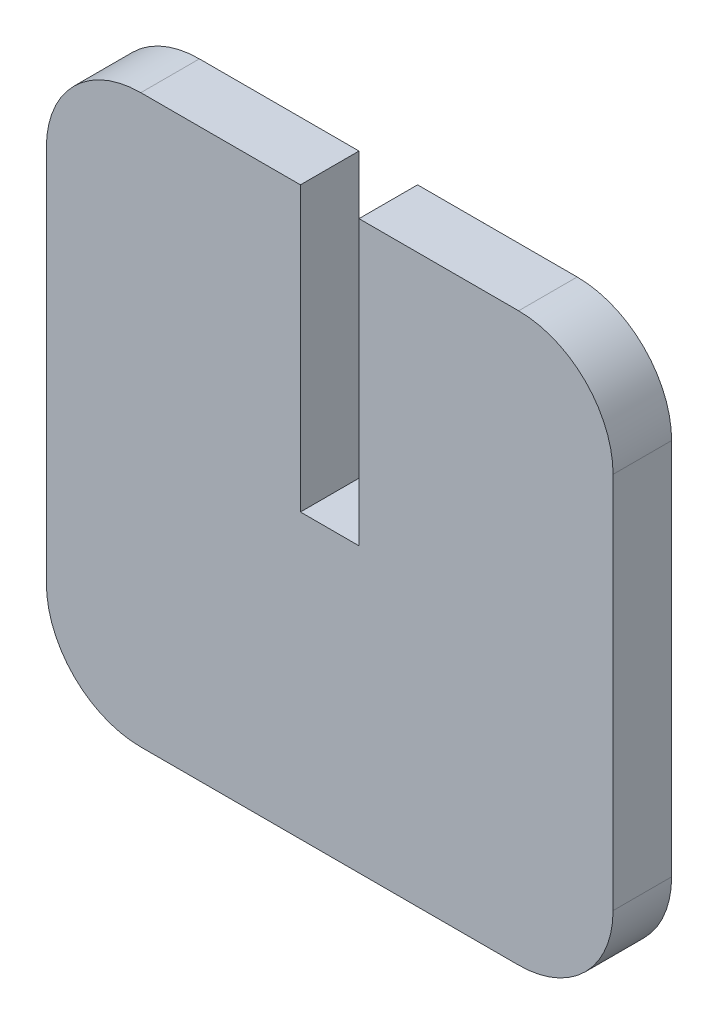
from build123d import *

# Parameters (mm, degrees)
SKETCH1_W           = 30
SKETCH1_H           = 30
BOSS_EXTRUDE1_DEPTH = 3.1
SKETCH2_W           = 3.1
SKETCH2_H           = 3.1
CUT_EXTRUDE1_DEPTH  = 15
FILLET1_R           = 5


with BuildPart() as part:
    # Sketch1 → Boss-Extrude1 (new body)
    with BuildSketch(Plane.XY):
        Rectangle(SKETCH1_W, SKETCH1_H)
    extrude(amount=BOSS_EXTRUDE1_DEPTH)

    # Sketch2 → Cut-Extrude1 (cut)
    with BuildSketch(Plane(origin=(0, 15, 0), x_dir=(1, 0, 0), z_dir=(0, 1, 0))):
        with Locations((0, -1.55)):
            Rectangle(SKETCH2_W, SKETCH2_H)
    extrude(amount=-CUT_EXTRUDE1_DEPTH, mode=Mode.SUBTRACT)

    # Fillet1
    fillet1_edges = [part.edges().sort_by_distance(p)[0] for p in [
        (15, -15, 1.55),
        (-15, -15, 1.55),
        (-15, 15, 1.55),
        (15, 15, 1.55),
    ]]
    fillet(fillet1_edges, radius=FILLET1_R)


solid = part.part
